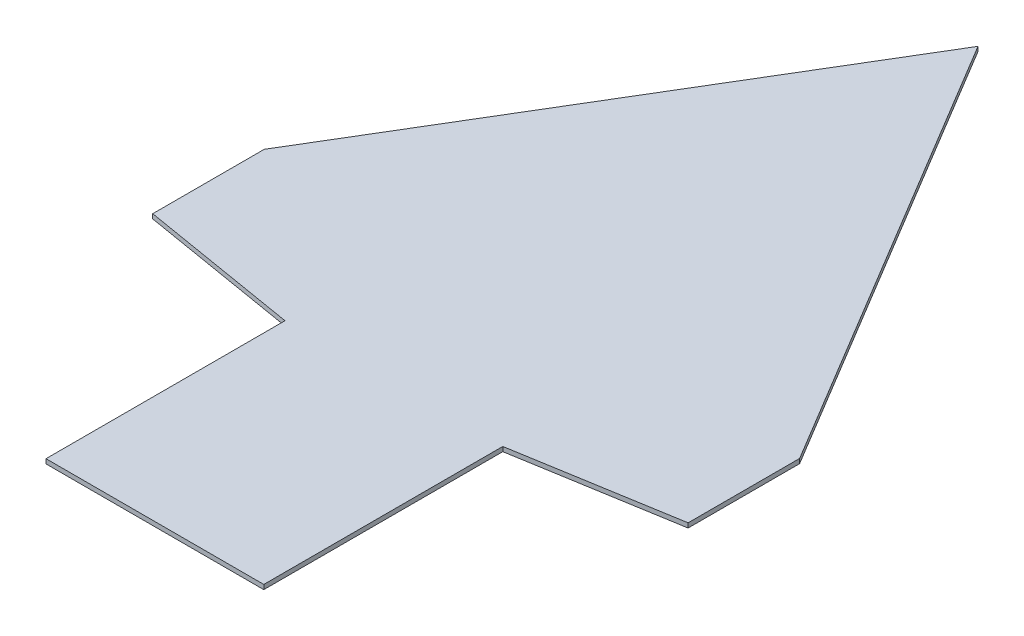
from build123d import *

# Parameters (mm, degrees)
BOSS_EXTRUDE1_DEPTH = 2.54


with BuildPart() as part:
    # Sketch1 → Boss-Extrude1 (new body)
    with BuildSketch(Plane(origin=(0, 0, 0), x_dir=(1, 0, 0), z_dir=(0, 1, 0))):
        Polygon((-37.543029513, -266.596478258), (-37.543029513, -400.386363558), (84.376970487, -400.386363558), (84.376970487, -266.596478258), (173.276970487, -251.746914939), (173.276970487, -189.32180024), (23.416970487, 60.389412071), (-126.443029513, -189.32180024), (-126.443029513, -251.746914939), align=None)
    extrude(amount=BOSS_EXTRUDE1_DEPTH)


solid = part.part
